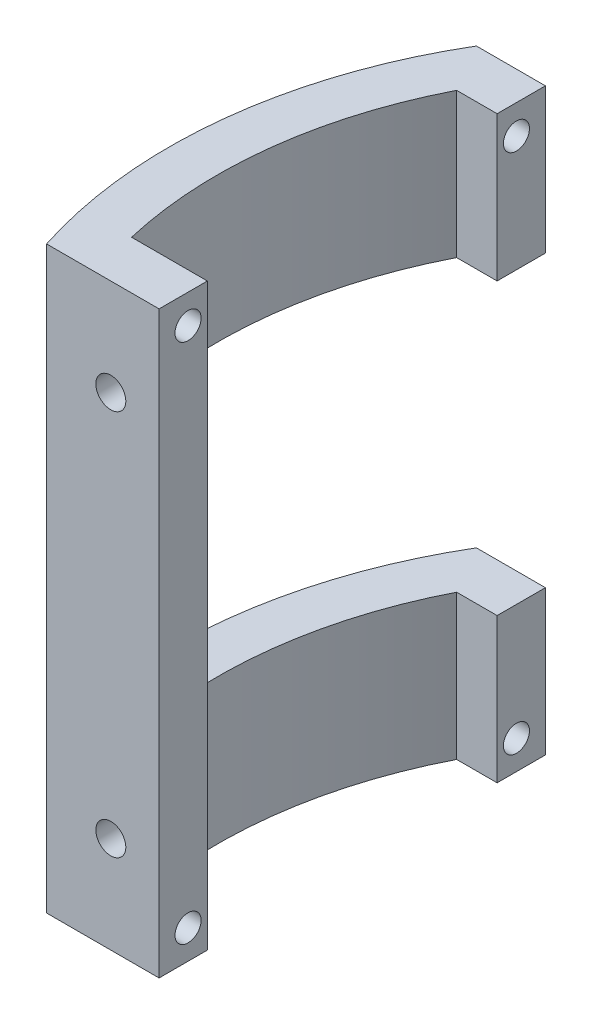
from build123d import *

# Parameters (mm, degrees)
BOSS_EXTRUDE1_DEPTH = 60
SKETCH2_R           = 1.55
CUT_EXTRUDE1_DEPTH  = 6
SKETCH4_W           = 35
SKETCH4_H           = 30
CUT_EXTRUDE3_DEPTH  = 15
SKETCH5_R           = 1.35
CUT_EXTRUDE4_DEPTH  = 5


with BuildPart() as part:
    # Sketch1 → Boss-Extrude1 (new body)
    with BuildSketch(Plane(origin=(0, 0, 0), x_dir=(1, 0, 0), z_dir=(0, 1, 0))):
        with BuildLine():
            ThreePointArc((-42.142615011, 25), (-48.692157925, 5.483954466), (-46.647615159, -15))
            Line((-46.647615159, -15), (-41.36423576, -15))
            Line((-41.36423576, -15), (-35, -15))
            Line((-35, -15), (-35, -10))
            Line((-35, -10), (-42.848570571, -10))
            ThreePointArc((-42.848570571, -10), (-43.67673377, 5.323807579), (-39.191835885, 20))
            Line((-39.191835885, 20), (-35, 20))
            Line((-35, 20), (-35, 25))
            Line((-35, 25), (-36.20773398, 25))
            Line((-36.20773398, 25), (-42.142615011, 25))
        make_face()
    extrude(amount=BOSS_EXTRUDE1_DEPTH)

    # Sketch2 → Cut-Extrude1 (cut, through all)
    with BuildSketch(Plane(origin=(0, 0, 10), x_dir=(-1, 0, 0), z_dir=(0, 0, -1))):
        with Locations((39.997615159, 50)):
            Circle(SKETCH2_R)
        with Locations((39.997615159, 10)):
            Circle(SKETCH2_R)
    extrude(amount=-CUT_EXTRUDE1_DEPTH, mode=Mode.SUBTRACT)

    # Sketch4 → Cut-Extrude3 (cut, through all)
    with BuildSketch(Plane(origin=(-35, 0, 0), x_dir=(0, 0, -1), z_dir=(1, 0, 0))):
        with Locations((7.5, 30)):
            Rectangle(SKETCH4_W, SKETCH4_H)
    extrude(amount=-CUT_EXTRUDE3_DEPTH, mode=Mode.SUBTRACT)

    # Sketch5 → Cut-Extrude4 (cut)
    with BuildSketch(Plane(origin=(-35, 0, 0), x_dir=(0, 0, -1), z_dir=(1, 0, 0))):
        with Locations((-12, 57)):
            Circle(SKETCH5_R)
        with Locations((22, 57)):
            Circle(SKETCH5_R)
        with Locations((-12, 3)):
            Circle(SKETCH5_R)
        with Locations((22, 3)):
            Circle(SKETCH5_R)
    extrude(amount=-CUT_EXTRUDE4_DEPTH, mode=Mode.SUBTRACT)


solid = part.part
